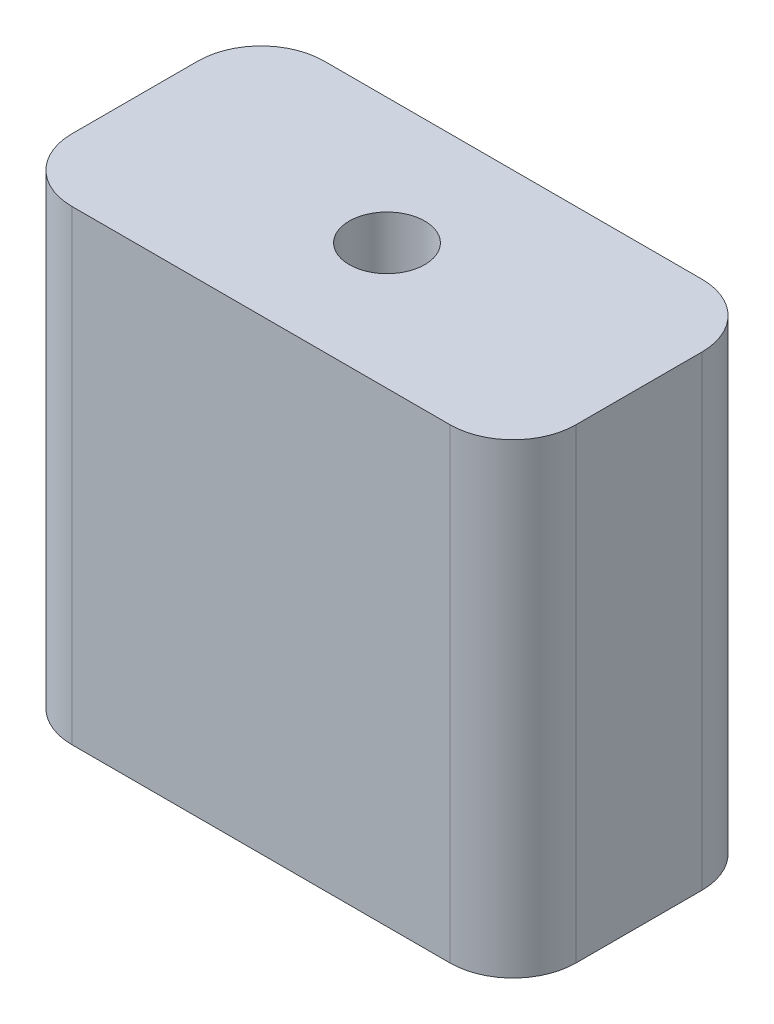
from build123d import *

# Parameters (mm, degrees)
SKETCH1_W           = 40
SKETCH1_H           = 20
BOSS_EXTRUDE1_DEPTH = 37
FILLET1_R           = 5
SKETCH2_R           = 3
CUT_EXTRUDE1_DEPTH  = 5


with BuildPart() as part:
    # Sketch1 → Boss-Extrude1 (new body)
    with BuildSketch(Plane(origin=(0, 0, 0), x_dir=(1, 0, 0), z_dir=(0, 1, 0))):
        Rectangle(SKETCH1_W, SKETCH1_H)
    extrude(amount=BOSS_EXTRUDE1_DEPTH)

    # Fillet1
    fillet1_edges = [part.edges().sort_by_distance(p)[0] for p in [
        (20, 18.5, 10),
        (-20, 18.5, 10),
        (-20, 18.5, -10),
        (20, 18.5, -10),
    ]]
    fillet(fillet1_edges, radius=FILLET1_R)

    # Sketch2 → Cut-Extrude1 (cut)
    with BuildSketch(Plane(origin=(0, 37, 0), x_dir=(1, 0, 0), z_dir=(0, 1, 0))):
        Circle(SKETCH2_R)
    extrude(amount=-CUT_EXTRUDE1_DEPTH, mode=Mode.SUBTRACT)


solid = part.part
